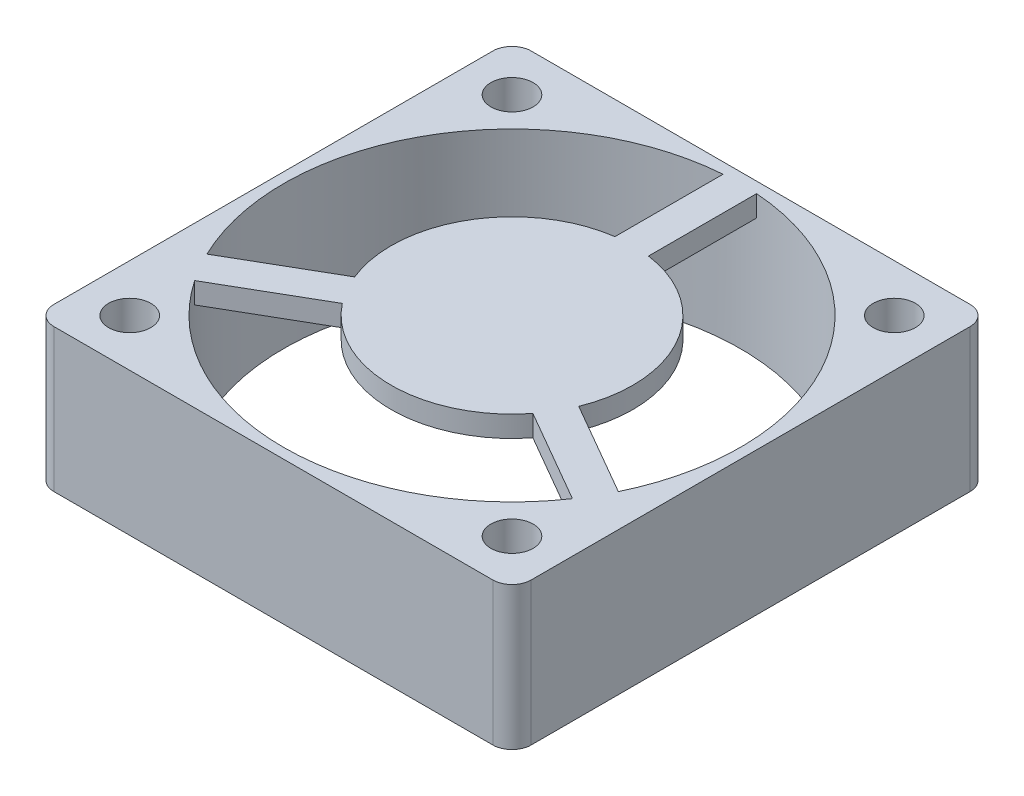
from build123d import *

# Parameters (mm, degrees)
SKETCH1_W           = 49.75
SKETCH1_H           = 49.75
BOSS_EXTRUDE1_DEPTH = 14.9
FILLET1_R           = 2
SKETCH2_R           = 2.2
CUT_EXTRUDE1_DEPTH  = 14.9
CUT_EXTRUDE2_DEPTH  = 3.7
SKETCH4_R           = 23.81
CUT_EXTRUDE3_DEPTH  = 39.203942859
SKETCH5_R           = 12.6
BOSS_EXTRUDE2_DEPTH = 2.2


with BuildPart() as part:
    # Sketch1 → Boss-Extrude1 (new body)
    with BuildSketch(Plane(origin=(0, 0, 0), x_dir=(1, 0, 0), z_dir=(0, 1, 0))):
        Rectangle(SKETCH1_W, SKETCH1_H)
    extrude(amount=BOSS_EXTRUDE1_DEPTH)

    # Fillet1
    fillet1_edges = [part.edges().sort_by_distance(p)[0] for p in [
        (24.875, 7.45, 24.875),
        (-24.875, 7.45, 24.875),
        (-24.875, 7.45, -24.875),
        (24.875, 7.45, -24.875),
    ]]
    fillet(fillet1_edges, radius=FILLET1_R)

    # Sketch2 → Cut-Extrude1 (cut)
    with BuildSketch(Plane(origin=(0, 14.9, 0), x_dir=(1, 0, 0), z_dir=(0, 1, 0))):
        with Locations(Location((-19.925, 19.925, 0), (0, 0, 270))):
            Circle(SKETCH2_R)
        with Locations(Location((19.925, 19.925, 0), (0, 0, 270))):
            Circle(SKETCH2_R)
        with Locations(Location((19.925, -19.925, 0), (0, 0, 270))):
            Circle(SKETCH2_R)
        with Locations(Location((-19.925, -19.925, 0), (0, 0, 270))):
            Circle(SKETCH2_R)
    extrude(amount=-CUT_EXTRUDE1_DEPTH, mode=Mode.SUBTRACT)

    # Sketch3 → Cut-Extrude2 (cut)
    with BuildSketch(Plane.XZ):
        Polygon((-17.985103096, 23.285), (-21.864896904, 23.285), (-23.804793809, 19.925), (-21.864896904, 16.565), (-17.985103096, 16.565), (-16.045206191, 19.925), align=None)
        Polygon((17.985103096, 23.285), (16.045206191, 19.925), (17.985103096, 16.565), (21.864896904, 16.565), (23.804793809, 19.925), (21.864896904, 23.285), align=None)
        Polygon((17.985103096, -16.565), (16.045206191, -19.925), (17.985103096, -23.285), (21.864896904, -23.285), (23.804793809, -19.925), (21.864896904, -16.565), align=None)
        Polygon((-21.864896904, -16.565), (-23.804793809, -19.925), (-21.864896904, -23.285), (-17.985103096, -23.285), (-16.045206191, -19.925), (-17.985103096, -16.565), align=None)
    extrude(amount=-CUT_EXTRUDE2_DEPTH, mode=Mode.SUBTRACT)

    # Sketch4 → Cut-Extrude3 (cut, through all)
    with BuildSketch(Plane(origin=(0, 14.9, 0), x_dir=(1, 0, 0), z_dir=(0, 1, 0))):
        with Locations(Location((0, 0, 0), (0, 0, 270))):
            Circle(SKETCH4_R)
    extrude(amount=-CUT_EXTRUDE3_DEPTH, mode=Mode.SUBTRACT)

    # Sketch5 → Boss-Extrude2 (add)
    with BuildSketch(Plane(origin=(0, 14.9, 0), x_dir=(1, 0, 0), z_dir=(0, 1, 0))):
        with BuildLine():
            ThreePointArc((-1.75, 12.477880429), (0, 12.6), (1.75, 12.477880429))
            Line((1.75, 12.477880429), (1.75, 23.745601698))
            ThreePointArc((1.75, 23.745601698), (0, 23.81), (-1.75, 23.745601698))
            Line((-1.75, 23.745601698), (-1.75, 12.477880429))
        make_face()
        Circle(SKETCH5_R)
        with BuildLine():
            ThreePointArc((-9.931161437, -7.754484671), (-10.911920088, -6.3), (-11.681161437, -4.723395758))
            Line((-11.681161437, -4.723395758), (-21.439294299, -10.357256392))
            ThreePointArc((-21.439294299, -10.357256392), (-20.620064864, -11.905), (-19.689294299, -13.388345306))
            Line((-19.689294299, -13.388345306), (-9.931161437, -7.754484671))
        make_face()
        with BuildLine():
            Line((21.439294299, -10.357256392), (11.681161437, -4.723395758))
            ThreePointArc((11.681161437, -4.723395758), (10.911920088, -6.3), (9.931161437, -7.754484671))
            Line((9.931161437, -7.754484671), (19.689294299, -13.388345306))
            ThreePointArc((19.689294299, -13.388345306), (20.620064864, -11.905), (21.439294299, -10.357256392))
        make_face()
    extrude(amount=-BOSS_EXTRUDE2_DEPTH)


solid = part.part
